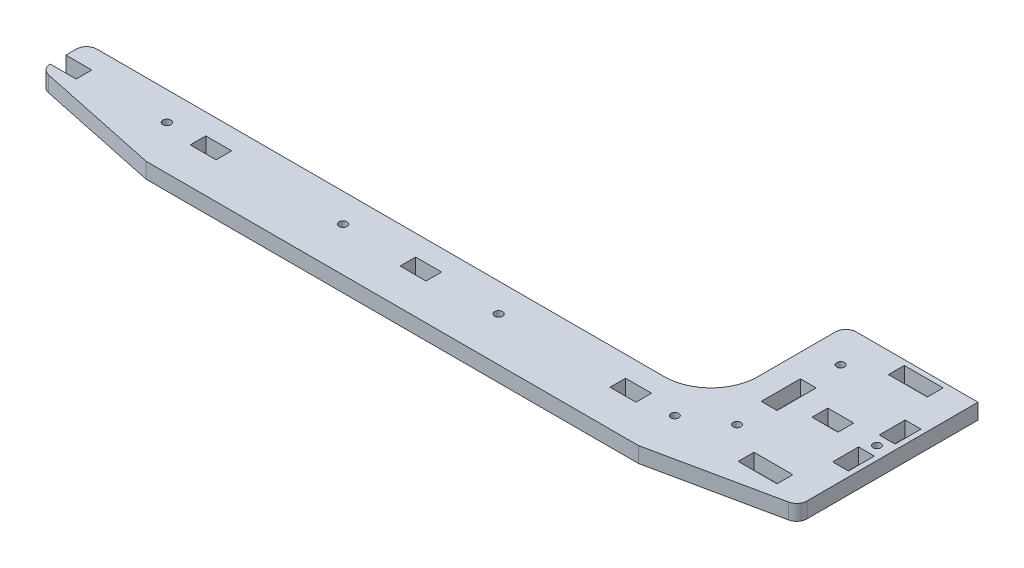
from build123d import *

# Parameters (mm, degrees)
SKETCH_1_R      = 1.55
SKETCH_1_W      = 10
SKETCH_1_H      = 6
SKETCH_1_R_2    = 1.5
SKETCH_1_W_2    = 15
SKETCH_1_H_2    = 6.1
SKETCH_1_W_3    = 6.1
SKETCH_1_H_3    = 10
SKETCH_1_H_4    = 15.1
EXTRUDE_1_DEPTH = 6


with BuildPart() as part:
    # Эскиз1 → Бобышка-Вытянуть1 (new body)
    with BuildSketch(Plane(origin=(0, 0, 0), x_dir=(1, 0, 0), z_dir=(0, 1, 0))):
        with BuildLine():
            Line((-168.683476523, -15.061578422), (-178.683476523, -15.061578422))
            ThreePointArc((-178.683476523, -15.061578422), (-177.790056525, -17.581332515), (-175.508896177, -18.97548726))
            Line((-175.508896177, -18.97548726), (-127.683476523, -29.061578422))
            Line((-127.683476523, -29.061578422), (62.316523477, -29.061578422))
            Line((62.316523477, -29.061578422), (110.14194313, -18.97548726))
            ThreePointArc((110.14194313, -18.97548726), (112.423103478, -17.581332515), (113.316523477, -15.061578422))
            Line((113.316523477, -15.061578422), (113.316523477, 50.938421578))
            Line((113.316523477, 50.938421578), (66.316523477, 50.938421578))
            ThreePointArc((66.316523477, 50.938421578), (63.488096352, 49.766848703), (62.316523477, 46.938421578))
            Line((62.316523477, 46.938421578), (62.316523477, 16.938421578))
            ThreePointArc((62.316523477, 16.938421578), (57.044445538, 4.210499517), (44.316523477, -1.061578422))
            Line((44.316523477, -1.061578422), (-174.683476523, -1.061578422))
            ThreePointArc((-174.683476523, -1.061578422), (-177.511903648, -2.233151297), (-178.683476523, -5.061578422))
            Line((-178.683476523, -5.061578422), (-178.683476523, -9.061578422))
            Line((-178.683476523, -9.061578422), (-168.683476523, -9.061578422))
            Line((-168.683476523, -9.061578422), (-168.683476523, -15.061578422))
        make_face()
        with Locations((-136.683476523, -12.061578422)):
            Circle(SKETCH_1_R, mode=Mode.SUBTRACT)
        with Locations((-119.683476523, -12.061578422)):
            Rectangle(SKETCH_1_W, SKETCH_1_H, mode=Mode.SUBTRACT)
        with Locations((-68.683476523, -12.061578422)):
            Circle(SKETCH_1_R, mode=Mode.SUBTRACT)
        with Locations((-38.683476523, -12.061578422)):
            Rectangle(SKETCH_1_W, SKETCH_1_H, mode=Mode.SUBTRACT)
        with Locations((-8.683476523, -12.061578422)):
            Circle(SKETCH_1_R, mode=Mode.SUBTRACT)
        with Locations((42.316523477, -12.061578422)):
            Rectangle(SKETCH_1_W, SKETCH_1_H, mode=Mode.SUBTRACT)
        with Locations((59.316523477, -12.061578422)):
            Circle(SKETCH_1_R_2, mode=Mode.SUBTRACT)
        with Locations((94.316523477, -12.061578422)):
            Rectangle(SKETCH_1_W_2, SKETCH_1_H_2, mode=Mode.SUBTRACT)
        with Locations((74.316523477, -3.061578422)):
            Circle(SKETCH_1_R_2, mode=Mode.SUBTRACT)
        with Locations((108.266523477, 7.938421578)):
            Rectangle(SKETCH_1_W_3, SKETCH_1_H_3, mode=Mode.SUBTRACT)
        with Locations((74.266523477, 16.938421578)):
            Rectangle(SKETCH_1_W_3, SKETCH_1_H_4, mode=Mode.SUBTRACT)
        with Locations((91.316523477, 16.938421578)):
            Rectangle(SKETCH_1_W, SKETCH_1_H_2, mode=Mode.SUBTRACT)
        with Locations((108.316523477, 16.938421578)):
            Circle(SKETCH_1_R_2, mode=Mode.SUBTRACT)
        with Locations((108.266523477, 25.938421578)):
            Rectangle(SKETCH_1_W_3, SKETCH_1_H_3, mode=Mode.SUBTRACT)
        with Locations((74.316523477, 36.938421578)):
            Circle(SKETCH_1_R_2, mode=Mode.SUBTRACT)
        with Locations((94.316523477, 45.938421578)):
            Rectangle(SKETCH_1_W_2, SKETCH_1_H_2, mode=Mode.SUBTRACT)
    extrude(amount=EXTRUDE_1_DEPTH)


solid = part.part
